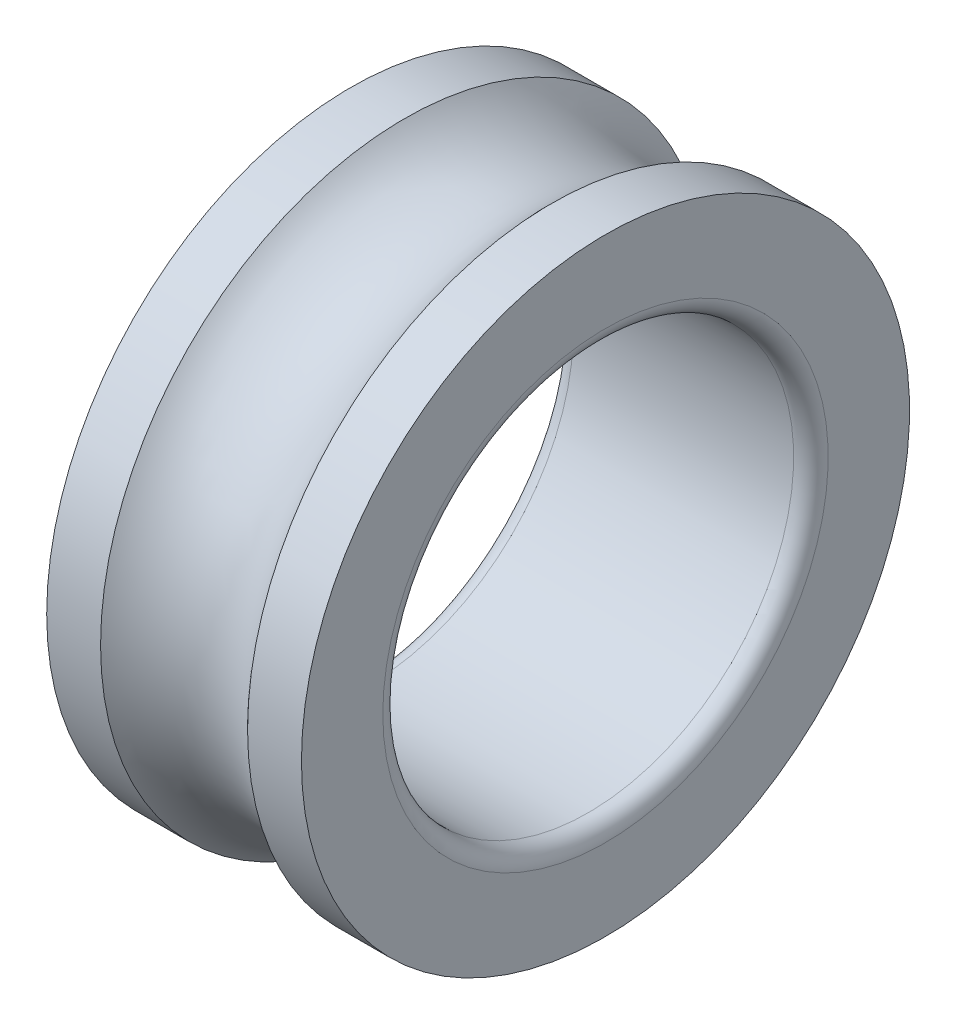
from build123d import *


with BuildPart() as part:
    # Sketch1 → Revolve1 (revolve)
    with BuildSketch(Plane.XY):
        with BuildLine():
            Line((8.94427191, 37), (15.5, 37))
            Line((15.5, 37), (15.5, 27.1))
            ThreePointArc((15.5, 27.1), (14.88492424, 25.61507576), (13.4, 25))
            Line((13.4, 25), (-13.4, 25))
            ThreePointArc((-13.4, 25), (-14.88492424, 25.61507576), (-15.5, 27.1))
            Line((-15.5, 27.1), (-15.5, 37))
            Line((-15.5, 37), (-8.94427191, 37))
            ThreePointArc((-8.94427191, 37), (0, 33), (8.94427191, 37))
        make_face()
    revolve(axis=Axis((-44.328053157, 0, 0), (1, 0, 0)))


solid = part.part
